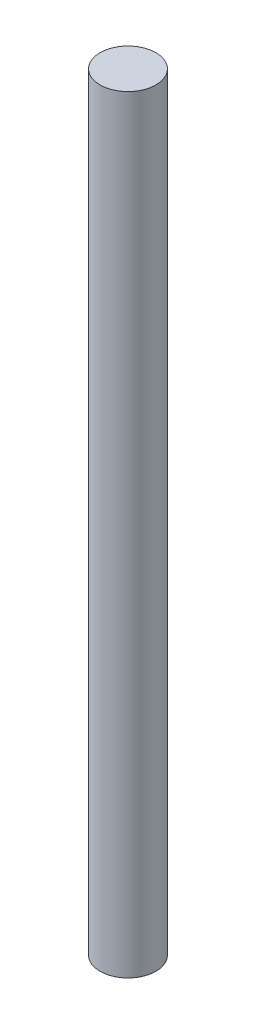
from build123d import *

# Parameters (mm, degrees)
ESBO_O1_R                = 4
RESSALTO_EXTRUS_O1_DEPTH = 110


with BuildPart() as part:
    # Esboço1 → Ressalto-extrusão1 (new body)
    with BuildSketch(Plane(origin=(0, 0, 0), x_dir=(1, 0, 0), z_dir=(0, 1, 0))):
        Circle(ESBO_O1_R)
    extrude(amount=RESSALTO_EXTRUS_O1_DEPTH)


solid = part.part
